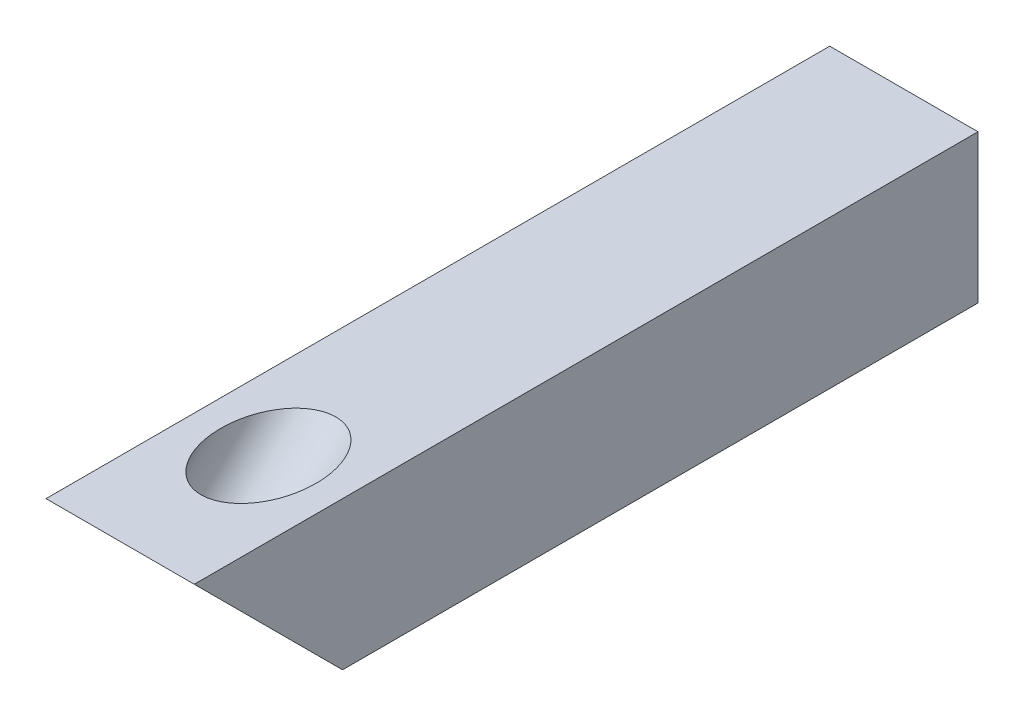
from build123d import *

# Parameters (mm, degrees)
SKETCH1_W           = 7
SKETCH1_H           = 7
BOSS_EXTRUDE1_DEPTH = 20
BOSS_EXTRUDE2_DEPTH = 7
SKETCH5_W           = 7
SKETCH5_H           = 7
BOSS_EXTRUDE4_DEPTH = 10
SKETCH4_R           = 2.25
CUT_EXTRUDE1_DEPTH  = 27.162950904


with BuildPart() as part:
    # Sketch1 → Boss-Extrude1 (new body)
    with BuildSketch(Plane.XY):
        with Locations((3.5, 3.5)):
            Rectangle(SKETCH1_W, SKETCH1_H)
    extrude(amount=BOSS_EXTRUDE1_DEPTH)

    # Sketch3 → Boss-Extrude2 (add)
    with BuildSketch(Plane(origin=(7, 0, 0), x_dir=(0, 0, -1), z_dir=(1, 0, 0))):
        Polygon((-20, 7), (-27, 7), (-20, 0), align=None)
    extrude(amount=-BOSS_EXTRUDE2_DEPTH)

    # Sketch5 → Boss-Extrude4 (add)
    with BuildSketch(Plane(origin=(0, 0, 0), x_dir=(-1, 0, 0), z_dir=(0, 0, -1))):
        with Locations((-3.5, 3.5)):
            Rectangle(SKETCH5_W, SKETCH5_H)
    extrude(amount=BOSS_EXTRUDE4_DEPTH)

    # Sketch4 → Cut-Extrude1 (cut, through all)
    with BuildSketch(Plane(origin=(0, -10, 10), x_dir=(1, 0, 0), z_dir=(0, -0.707106781, 0.707106781))):
        with Locations((3.5, 19.091883092)):
            Circle(SKETCH4_R)
    extrude(amount=-CUT_EXTRUDE1_DEPTH, mode=Mode.SUBTRACT)


solid = part.part
